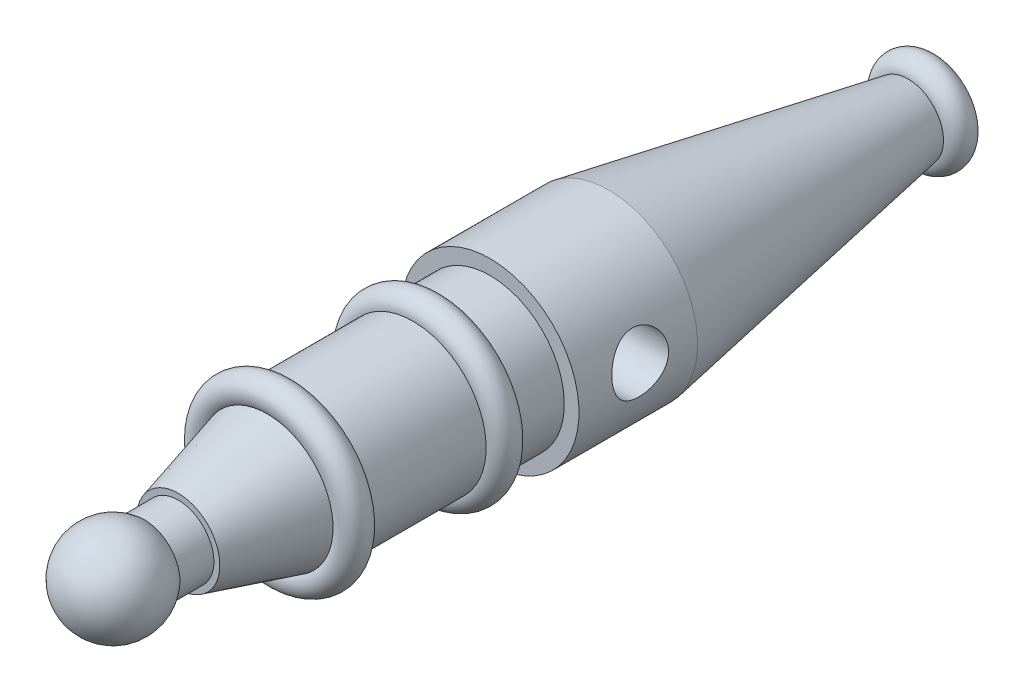
from build123d import *

# Parameters (mm, degrees)
SKETCH2_R               = 5.802230713
CUT_EXTRUDE1_DEPTH      = 50
SKETCH3_R               = 4.75
CUT_EXTRUDE2_DEPTH      = 16.0000001
CUT_EXTRUDE2_DEPTH_BACK = 16.0000001


with BuildPart() as part:
    # Sketch1 → Revolve2 (revolve)
    with BuildSketch(Plane(origin=(0, 0, 0), x_dir=(0, 0, -1), z_dir=(1, 0, 0))):
        with BuildLine():
            Line((-37.897522785, 6), (-37.897522785, 7))
            Line((-37.897522785, 7), (-22.897522785, 11.09704556))
            ThreePointArc((-22.897522785, 11.09704556), (-21.487003093, 14.911658932), (-18.333179942, 12.343733598))
            Line((-18.333179942, 12.343733598), (1.666820058, 12.343733598))
            ThreePointArc((1.666820058, 12.343733598), (4.071063628, 14.998348062), (6.661802335, 12.525406889))
            Line((6.661802335, 12.525406889), (14.661802335, 12.525406889))
            Line((14.661802335, 12.525406889), (14.661802335, 14.998348062))
            Line((14.661802335, 14.998348062), (34.661802335, 14.998348062))
            Line((34.661802335, 14.998348062), (85.11031203, 6))
            ThreePointArc((85.11031203, 6), (87.701439424, 8.300271241), (90.102477215, 5.802230713))
            Line((90.102477215, 5.802230713), (90.102477215, 0))
            Line((90.102477215, 0), (-56.897522785, 0))
            ThreePointArc((-56.897522785, 0), (-52.189025407, 7.291502622), (-43.606020163, 6))
            Line((-43.606020163, 6), (-37.897522785, 6))
        make_face()
    revolve(axis=Axis((0, 0, -90.102477215), (0, 0, 1)))

    # Sketch2 → Cut-Extrude1 (cut)
    with BuildSketch(Plane(origin=(0, 0, -90.102477215), x_dir=(-1, 0, 0), z_dir=(0, 0, -1))):
        Circle(SKETCH2_R)
    extrude(amount=-CUT_EXTRUDE1_DEPTH, mode=Mode.SUBTRACT)

    # Sketch3 → Cut-Extrude2 (cut, two sides)
    with BuildSketch(Plane(origin=(0, 0, 0), x_dir=(0, 0, -1), z_dir=(1, 0, 0))) as cut_extrude2_sk:
        with Locations((25.083429827, 1.678883726)):
            Circle(SKETCH3_R)
    extrude(amount=CUT_EXTRUDE2_DEPTH, mode=Mode.SUBTRACT)
    extrude(cut_extrude2_sk.sketch, amount=-CUT_EXTRUDE2_DEPTH_BACK, mode=Mode.SUBTRACT)


solid = part.part
